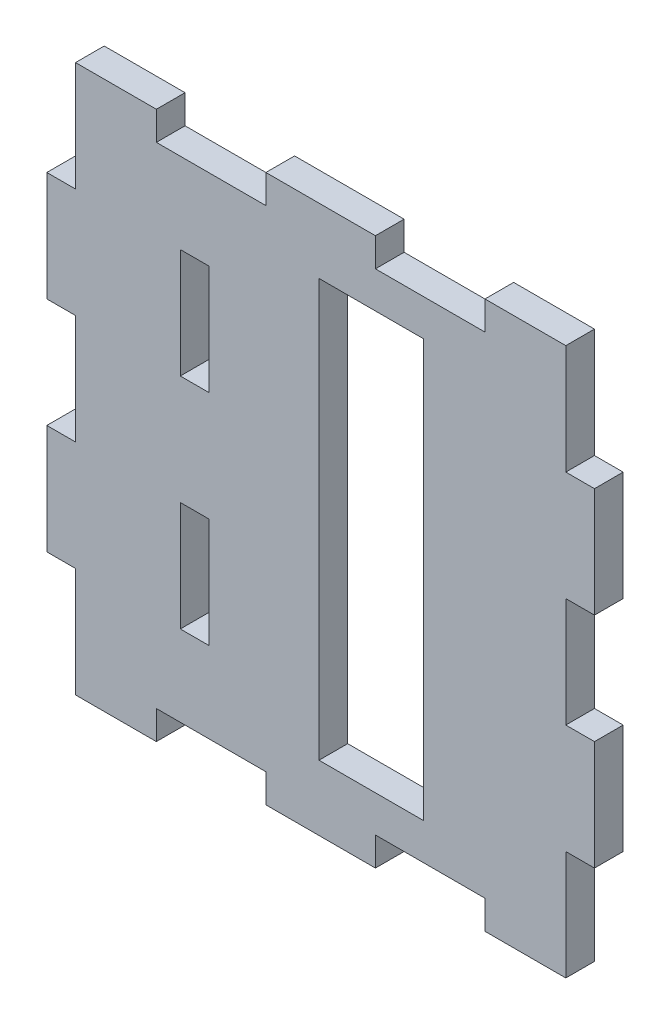
from build123d import *

# Parameters (mm, degrees)
CROQUIS2_W              = 20
CROQUIS2_H              = 80
CROQUIS2_W_2            = 5.5
CROQUIS2_H_2            = 21
SALIENTE_EXTRUIR1_DEPTH = 5.5
CROQUIS3_W              = 5.5
CROQUIS3_H              = 21
SALIENTE_EXTRUIR2_DEPTH = 2.5
CROQUIS4_W              = 15.5
CROQUIS4_H              = 5.5
CROQUIS4_W_2            = 21
SALIENTE_EXTRUIR3_DEPTH = 2.5
CROQUIS5_W              = 5.5
CROQUIS5_H              = 21
SALIENTE_EXTRUIR4_DEPTH = 2.5
CROQUIS6_W              = 15.5
CROQUIS6_H              = 5.5
CROQUIS6_W_2            = 21
SALIENTE_EXTRUIR5_DEPTH = 2.5


with BuildPart() as part:
    # Croquis2 → Saliente-Extruir1 (new body)
    with BuildSketch(Plane.XY):
        Polygon((-47, 50), (-47, 31.5), (-50, 31.5), (-50, 10.5), (-47, 10.5), (-47, -10.5), (-50, -10.5), (-50, -31.5), (-47, -31.5), (-47, -50), (-31.5, -50), (-31.5, -47), (-10.5, -47), (-10.5, -50), (10.5, -50), (10.5, -47), (31.5, -47), (31.5, -50), (47, -50), (47, -31.5), (50, -31.5), (50, -10.5), (47, -10.5), (47, 10.5), (50, 10.5), (50, 31.5), (47, 31.5), (47, 50), (31.5, 50), (31.5, 47), (10.5, 47), (10.5, 50), (-10.5, 50), (-10.5, 47), (-31.5, 47), (-31.5, 50), align=None)
        with Locations((9.68, 0)):
            Rectangle(CROQUIS2_W, CROQUIS2_H, mode=Mode.SUBTRACT)
        with Locations((-24.16, 21)):
            Rectangle(CROQUIS2_W_2, CROQUIS2_H_2, mode=Mode.SUBTRACT)
        with Locations((-24.16, -21)):
            Rectangle(CROQUIS2_W_2, CROQUIS2_H_2, mode=Mode.SUBTRACT)
    extrude(amount=SALIENTE_EXTRUIR1_DEPTH)

    # Croquis3 → Saliente-Extruir2 (add)
    with BuildSketch(Plane.ZY.offset(50)):
        with Locations((2.75, -21)):
            Rectangle(CROQUIS3_W, CROQUIS3_H)
        with Locations((2.75, 21)):
            Rectangle(CROQUIS3_W, CROQUIS3_H)
    extrude(amount=SALIENTE_EXTRUIR2_DEPTH)

    # Croquis4 → Saliente-Extruir3 (add)
    with BuildSketch(Plane(origin=(0, 50, 0), x_dir=(1, 0, 0), z_dir=(0, 1, 0))):
        with Locations((39.25, -2.75)):
            Rectangle(CROQUIS4_W, CROQUIS4_H)
        with Locations((0, -2.75)):
            Rectangle(CROQUIS4_W_2, CROQUIS4_H)
        with Locations((-39.25, -2.75)):
            Rectangle(CROQUIS4_W, CROQUIS4_H)
    extrude(amount=SALIENTE_EXTRUIR3_DEPTH)

    # Croquis5 → Saliente-Extruir4 (add)
    with BuildSketch(Plane(origin=(50, 0, 0), x_dir=(0, 0, -1), z_dir=(1, 0, 0))):
        with Locations((-2.75, -21)):
            Rectangle(CROQUIS5_W, CROQUIS5_H)
        with Locations((-2.75, 21)):
            Rectangle(CROQUIS5_W, CROQUIS5_H)
    extrude(amount=SALIENTE_EXTRUIR4_DEPTH)

    # Croquis6 → Saliente-Extruir5 (add)
    with BuildSketch(Plane.XZ.offset(50)):
        with Locations((39.25, 2.75)):
            Rectangle(CROQUIS6_W, CROQUIS6_H)
        with Locations((0, 2.75)):
            Rectangle(CROQUIS6_W_2, CROQUIS6_H)
        with Locations((-39.25, 2.75)):
            Rectangle(CROQUIS6_W, CROQUIS6_H)
    extrude(amount=SALIENTE_EXTRUIR5_DEPTH)


solid = part.part
